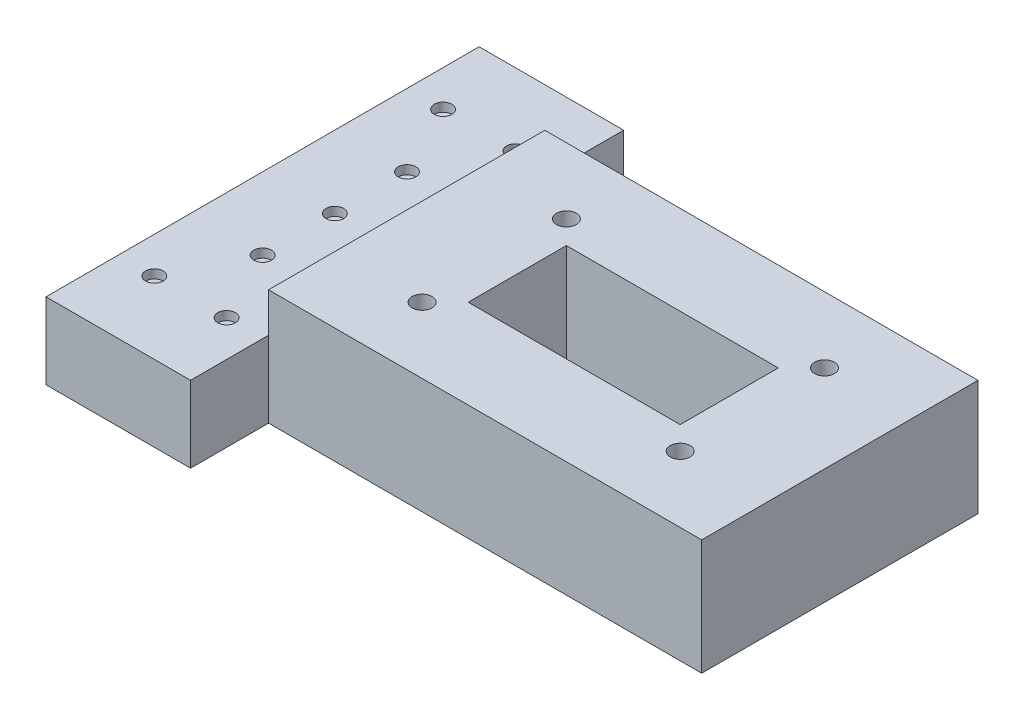
from build123d import *

# Parameters (mm, degrees)
SKETCH8_W           = 131.76
SKETCH8_H           = 95.69
SKETCH8_R           = 3.43
SKETCH8_W_2         = 73.4
SKETCH8_H_2         = 33.99
BOSS_EXTRUDE4_DEPTH = 40
SKETCH9_R           = 8
CUT_EXTRUDE2_DEPTH  = 8
SKETCH12_W          = 9.12
SKETCH12_H          = 95.69
BOSS_EXTRUDE5_DEPTH = 40
BOSS_EXTRUDE6_DEPTH = 26.38
SKETCH15_R          = 3.05
CUT_EXTRUDE4_DEPTH  = 3.05
SKETCH14_R          = 3.05
CUT_EXTRUDE3_DEPTH  = 3.05


with BuildPart() as part:
    # Sketch8 → Boss-Extrude4 (new body)
    with BuildSketch(Plane(origin=(0, 0, 0), x_dir=(1, 0, 0), z_dir=(0, 1, 0))):
        with Locations((-55.88, 37.845)):
            Rectangle(SKETCH8_W, SKETCH8_H)
        with Locations((-100.58, 12.85)):
            Circle(SKETCH8_R, mode=Mode.SUBTRACT)
        with Locations((-100.58, 62.84)):
            Circle(SKETCH8_R, mode=Mode.SUBTRACT)
        with Locations((-11.18, 62.84)):
            Circle(SKETCH8_R, mode=Mode.SUBTRACT)
        with Locations((-11.18, 12.85)):
            Circle(SKETCH8_R, mode=Mode.SUBTRACT)
        with Locations((-55.88, 37.845)):
            Rectangle(SKETCH8_W_2, SKETCH8_H_2, mode=Mode.SUBTRACT)
    extrude(amount=BOSS_EXTRUDE4_DEPTH)

    # Sketch9 → Cut-Extrude2 (cut)
    with BuildSketch(Plane.XZ):
        with Locations((-100.58, -12.85)):
            Circle(SKETCH9_R)
        with Locations((-11.18, -12.85)):
            Circle(SKETCH9_R)
        with Locations((-11.18, -62.84)):
            Circle(SKETCH9_R)
        with Locations((-100.58, -62.84)):
            Circle(SKETCH9_R)
    extrude(amount=-CUT_EXTRUDE2_DEPTH, mode=Mode.SUBTRACT)

    # Sketch12 → Boss-Extrude5 (add)
    with BuildSketch(Plane.XZ):
        with Locations((-126.32, -37.845)):
            Rectangle(SKETCH12_W, SKETCH12_H)
        with Locations((14.56, -37.845)):
            Rectangle(SKETCH12_W, SKETCH12_H)
    extrude(amount=-BOSS_EXTRUDE5_DEPTH)

    # Sketch13 → Boss-Extrude6 (add)
    with BuildSketch(Plane.XZ):
        Polygon((-130.88, -85.69), (-130.88, 10), (-130.88, 37.02), (-180.93, 37.02), (-180.93, -112.98), (-130.88, -112.98), align=None)
    extrude(amount=-BOSS_EXTRUDE6_DEPTH)

    # Sketch15 → Cut-Extrude4 (cut)
    with BuildSketch(Plane(origin=(0, 26.38, 0), x_dir=(1, 0, 0), z_dir=(0, 1, 0))):
        with Locations((-168.4175, 87.98)):
            Circle(SKETCH15_R)
        with Locations((-143.3925, 87.98)):
            Circle(SKETCH15_R)
        with Locations((-155.905, 62.98)):
            Circle(SKETCH15_R)
        with Locations((-155.905, 37.98)):
            Circle(SKETCH15_R)
        with Locations((-155.905, 12.98)):
            Circle(SKETCH15_R)
        with Locations((-168.4175, -12.02)):
            Circle(SKETCH15_R)
        with Locations((-143.3925, -12.02)):
            Circle(SKETCH15_R)
    extrude(amount=-CUT_EXTRUDE4_DEPTH, mode=Mode.SUBTRACT)

    # Sketch14 → Cut-Extrude3 (cut)
    with BuildSketch(Plane(origin=(0, 26.38, 0), x_dir=(1, 0, 0), z_dir=(0, 1, 0))):
        with Locations((-105.88, -22.5125)):
            Circle(SKETCH14_R)
        with Locations((-105.88, -47.5375)):
            Circle(SKETCH14_R)
        with BuildLine():
            ThreePointArc((-77.83, -35.025), (-80.88, -31.975), (-83.93, -35.025))
            Line((-83.93, -35.025), (-77.83, -35.025))
        make_face()
        with BuildLine():
            Line((-77.83, -35.025), (-83.93, -35.025))
            ThreePointArc((-83.93, -35.025), (-80.88, -38.075), (-77.83, -35.025))
        make_face()
        with BuildLine():
            ThreePointArc((-52.83, -22.5125), (-53.723324317, -20.355824317), (-55.88, -19.4625))
            Line((-55.88, -19.4625), (-55.88, -25.5625))
            ThreePointArc((-55.88, -25.5625), (-53.723324317, -24.669175683), (-52.83, -22.5125))
        make_face()
        with BuildLine():
            Line((-55.88, -25.5625), (-55.88, -19.4625))
            ThreePointArc((-55.88, -19.4625), (-58.93, -22.5125), (-55.88, -25.5625))
        make_face()
        with BuildLine():
            ThreePointArc((-55.88, -44.4875), (-58.93, -47.5375), (-55.88, -50.5875))
            Line((-55.88, -50.5875), (-55.88, -44.4875))
        make_face()
        with BuildLine():
            Line((-55.88, -44.4875), (-55.88, -50.5875))
            ThreePointArc((-55.88, -50.5875), (-53.723324317, -49.694175683), (-52.83, -47.5375))
            ThreePointArc((-52.83, -47.5375), (-53.723324317, -45.380824317), (-55.88, -44.4875))
        make_face()
        with BuildLine():
            ThreePointArc((-33.93, -35.025), (-33.036675683, -37.181675683), (-30.88, -38.075))
            Line((-30.88, -38.075), (-30.88, -35.025))
            Line((-30.88, -35.025), (-33.93, -35.025))
        make_face()
        with BuildLine():
            Line((-30.88, -35.025), (-30.88, -38.075))
            ThreePointArc((-30.88, -38.075), (-28.723324317, -37.181675683), (-27.83, -35.025))
            Line((-27.83, -35.025), (-30.88, -35.025))
        make_face()
        with BuildLine():
            ThreePointArc((-27.83, -35.025), (-28.723324317, -32.868324317), (-30.88, -31.975))
            Line((-30.88, -31.975), (-30.88, -35.025))
            Line((-30.88, -35.025), (-27.83, -35.025))
        make_face()
        with BuildLine():
            Line((-30.88, -35.025), (-30.88, -31.975))
            ThreePointArc((-30.88, -31.975), (-33.036675683, -32.868324317), (-33.93, -35.025))
            Line((-33.93, -35.025), (-30.88, -35.025))
        make_face()
        with BuildLine():
            ThreePointArc((-2.83, -22.5125), (-3.723324317, -20.355824317), (-5.88, -19.4625))
            Line((-5.88, -19.4625), (-5.88, -25.5625))
            ThreePointArc((-5.88, -25.5625), (-3.723324317, -24.669175683), (-2.83, -22.5125))
        make_face()
        with BuildLine():
            Line((-5.88, -25.5625), (-5.88, -19.4625))
            ThreePointArc((-5.88, -19.4625), (-8.93, -22.5125), (-5.88, -25.5625))
        make_face()
        with BuildLine():
            ThreePointArc((-5.88, -44.4875), (-8.93, -47.5375), (-5.88, -50.5875))
            Line((-5.88, -50.5875), (-5.88, -44.4875))
        make_face()
        with BuildLine():
            Line((-5.88, -44.4875), (-5.88, -50.5875))
            ThreePointArc((-5.88, -50.5875), (-3.723324317, -49.694175683), (-2.83, -47.5375))
            ThreePointArc((-2.83, -47.5375), (-3.723324317, -45.380824317), (-5.88, -44.4875))
        make_face()
    extrude(amount=-CUT_EXTRUDE3_DEPTH, mode=Mode.SUBTRACT)


solid = part.part
